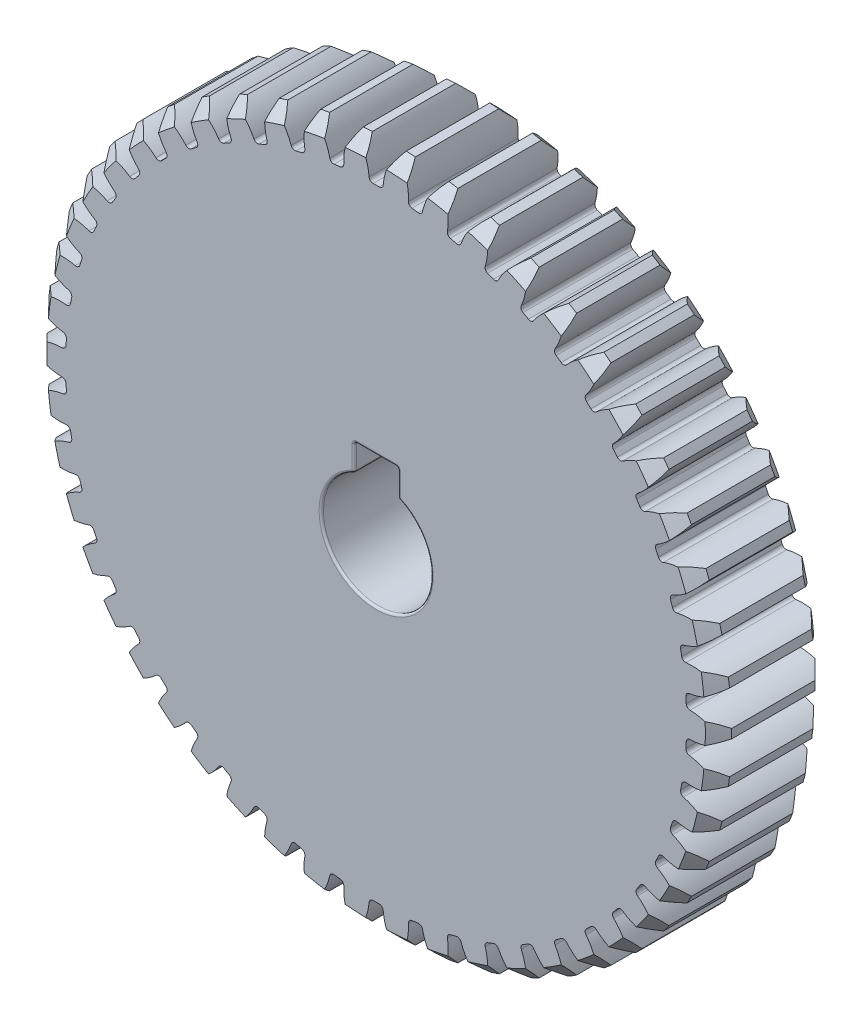
from build123d import *

# Parameters (mm, degrees)
SKETCH1_R                = 31.2
BOSS_EXTRUDE1_DEPTH      = 5
CUT_EXTRUDE1_DEPTH       = 6
FILLET1_R                = 0.36
CHAMFER1_SIZE            = 1.2
CIRPATTERN1_COUNT        = 50
FILLET1_OF_CIRPATTERN1_R = 0.36
CUT_EXTRUDE2_DEPTH       = 11.0000001
FILLET2_R                = 0.2


with BuildPart() as part:
    # Sketch1 → Boss-Extrude1 (new body, symmetric)
    with BuildSketch(Plane.XY):
        Circle(SKETCH1_R)
    extrude(amount=BOSS_EXTRUDE1_DEPTH, both=True)

    # Sketch2 → Cut-Extrude1 (cut, symmetric)
    with BuildSketch(Plane.XY):
        with BuildLine():
            ThreePointArc((1.546487783, 31.161649115), (0.876974651, 29.794412508), (0.624666042, 28.293105032))
            ThreePointArc((0.624666042, 28.293105032), (0, 28.3), (-0.624666042, 28.293105032))
            ThreePointArc((-0.624666042, 28.293105032), (-0.876974651, 29.794412508), (-1.546487783, 31.161649115))
            ThreePointArc((-1.546487783, 31.161649115), (0, 31.2), (1.546487783, 31.161649115))
        make_face()
    cut_extrude1 = extrude(amount=CUT_EXTRUDE1_DEPTH, both=True, mode=Mode.SUBTRACT)

    # Fillet1
    fillet1_edges = [part.edges().sort_by_distance(p)[0] for p in [
        (0.624666042, 28.293105032, 0),
        (-0.624666042, 28.293105032, 0),
    ]]
    fillet(fillet1_edges, radius=FILLET1_R)

    # Chamfer1
    chamfer1_edges = [part.edges().sort_by_distance(p)[0] for p in [
        (-21.508016891, -22.601885085, -5),
        (-21.508016891, -22.601885085, 5),
    ]]
    chamfer(chamfer1_edges, length=CHAMFER1_SIZE)

    # CirPattern1: Cut-Extrude1 ×50 about axis
    cirpattern1_axis = Axis((0, 0, 0), (0, 0, 1))
    for i in range(1, CIRPATTERN1_COUNT):
        add(cut_extrude1.rotate(cirpattern1_axis, i * 360 / CIRPATTERN1_COUNT), mode=Mode.SUBTRACT)

    # Fillet1 of CirPattern1
    fillet1_of_cirpattern1_edges = [part.edges().sort_by_distance(p)[0] for p in [
        (-2.926325978, 28.148296863, 0),
        (-4.165806704, 27.991714033, 0),
        (-6.431168089, 27.559573237, 0),
        (-7.641250107, 27.248876982, 0),
        (-9.834586837, 26.536218678, 0),
        (-10.996186431, 26.076308864, 0),
        (-13.082908276, 25.094372099, 0),
        (-14.177706326, 24.492501778, 0),
        (-16.124904436, 23.256772281, 0),
        (-17.135635323, 22.522433307, 0),
        (-18.91260122, 21.052399271, 0),
        (-19.823325114, 20.19717261, 0),
        (-21.402034986, 18.516017349, 0),
        (-22.198389227, 17.553390434, 0),
        (-23.553945874, 15.687626772, 0),
        (-24.22337148, 14.632780806, 0),
        (-25.334396966, 12.61183295, 0),
        (-25.866336696, 11.481403483, 0),
        (-26.715309484, 9.337142988, 0),
        (-27.101374329, 8.148957569, 0),
        (-27.674905612, 5.915200703, 0),
        (-27.9090071, 4.687997726, 0),
        (-28.198051947, 2.39997217, 0),
        (-28.276498157, 1.153105358, 0),
        (-28.276498157, -1.153105358, 0),
        (-28.198051947, -2.39997217, 0),
        (-27.9090071, -4.687997726, 0),
        (-27.674905612, -5.915200703, 0),
        (-27.101374329, -8.148957569, 0),
        (-26.715309484, -9.337142988, 0),
        (-25.866336696, -11.481403483, 0),
        (-25.334396966, -12.61183295, 0),
        (-24.22337148, -14.632780806, 0),
        (-23.553945874, -15.687626772, 0),
        (-22.198389227, -17.553390434, 0),
        (-21.402034986, -18.516017349, 0),
        (-19.823325114, -20.19717261, 0),
        (-18.91260122, -21.052399271, 0),
        (-17.135635323, -22.522433307, 0),
        (-16.124904436, -23.256772281, 0),
        (-14.177706326, -24.492501778, 0),
        (-13.082908276, -25.094372099, 0),
        (-10.996186431, -26.076308864, 0),
        (-9.834586837, -26.536218678, 0),
        (-7.641250107, -27.248876982, 0),
        (-6.431168089, -27.559573237, 0),
        (-4.165806704, -27.991714033, 0),
        (-2.926325978, -28.148296863, 0),
        (-0.624666042, -28.293105032, 0),
        (0.624666042, -28.293105032, 0),
        (2.926325978, -28.148296863, 0),
        (4.165806704, -27.991714033, 0),
        (6.431168089, -27.559573237, 0),
        (7.641250107, -27.248876982, 0),
        (9.834586837, -26.536218678, 0),
        (10.996186431, -26.076308864, 0),
        (13.082908276, -25.094372099, 0),
        (14.177706326, -24.492501778, 0),
        (16.124904436, -23.256772281, 0),
        (17.135635323, -22.522433307, 0),
        (18.91260122, -21.052399271, 0),
        (19.823325114, -20.19717261, 0),
        (21.402034986, -18.516017349, 0),
        (22.198389227, -17.553390434, 0),
        (23.553945874, -15.687626772, 0),
        (24.22337148, -14.632780806, 0),
        (25.334396966, -12.61183295, 0),
        (25.866336696, -11.481403483, 0),
        (26.715309484, -9.337142988, 0),
        (27.101374329, -8.148957569, 0),
        (27.674905612, -5.915200703, 0),
        (27.9090071, -4.687997726, 0),
        (28.198051947, -2.39997217, 0),
        (28.276498157, -1.153105358, 0),
        (28.276498157, 1.153105358, 0),
        (28.198051947, 2.39997217, 0),
        (27.9090071, 4.687997726, 0),
        (27.674905612, 5.915200703, 0),
        (27.101374329, 8.148957569, 0),
        (26.715309484, 9.337142988, 0),
        (25.866336696, 11.481403483, 0),
        (25.334396966, 12.61183295, 0),
        (24.22337148, 14.632780806, 0),
        (23.553945874, 15.687626772, 0),
        (22.198389227, 17.553390434, 0),
        (21.402034986, 18.516017349, 0),
        (19.823325114, 20.19717261, 0),
        (18.91260122, 21.052399271, 0),
        (17.135635323, 22.522433307, 0),
        (16.124904436, 23.256772281, 0),
        (14.177706326, 24.492501778, 0),
        (13.082908276, 25.094372099, 0),
        (10.996186431, 26.076308864, 0),
        (9.834586837, 26.536218678, 0),
        (7.641250107, 27.248876982, 0),
        (6.431168089, 27.559573237, 0),
        (4.165806704, 27.991714033, 0),
        (2.926325978, 28.148296863, 0),
    ]]
    fillet(fillet1_of_cirpattern1_edges, radius=FILLET1_OF_CIRPATTERN1_R)

    # Sketch3 → Cut-Extrude2 (cut, through all)
    with BuildSketch(Plane.XY.offset(5)):
        with BuildLine():
            Line((-2, 4.582575695), (-2, 7))
            Line((-2, 7), (2, 7))
            Line((2, 7), (2, 4.582575695))
            ThreePointArc((2, 4.582575695), (0, -5), (-2, 4.582575695))
        make_face()
    extrude(amount=-CUT_EXTRUDE2_DEPTH, mode=Mode.SUBTRACT)

    # Fillet2
    fillet2_edges = [part.edges().sort_by_distance(p)[0] for p in [
        (0, -5, -5),
        (2, 4.582575695, 0),
        (-2, 5.791287847, -5),
        (-2, 4.582575695, 0),
        (0, 7, -5),
        (-2, 7, 0),
        (2, 5.791287847, -5),
        (2, 7, 0),
        (0, -5, 5),
        (2, 5.791287847, 5),
        (0, 7, 5),
        (-2, 5.791287847, 5),
    ]]
    fillet(fillet2_edges, radius=FILLET2_R)


solid = part.part
